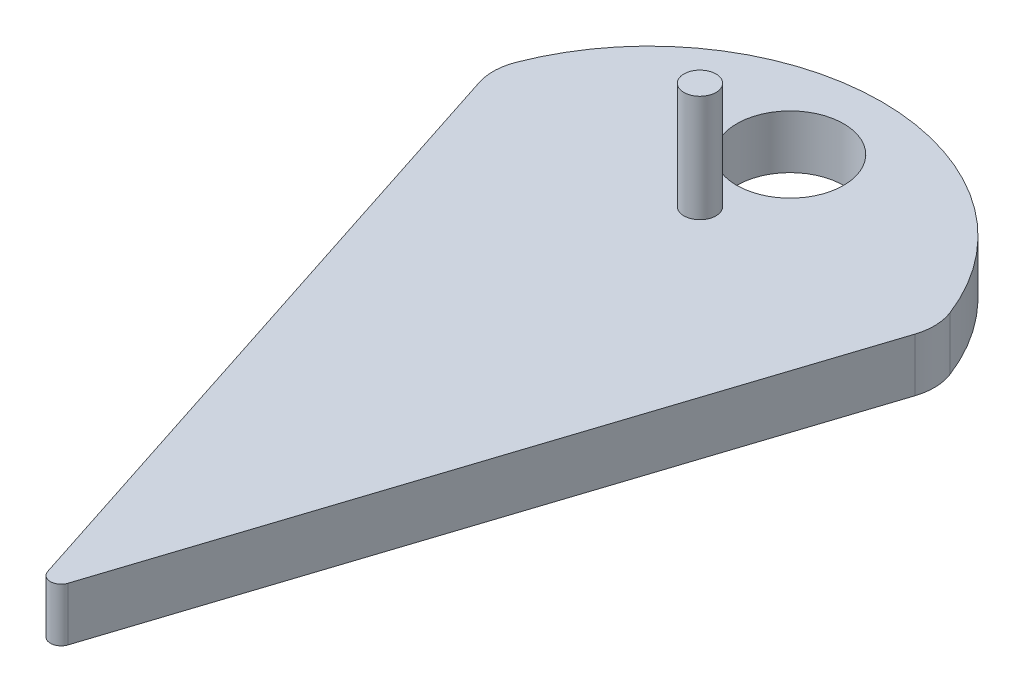
from build123d import *

# Parameters (mm, degrees)
SKETCH4_R           = 5
BOSS_EXTRUDE1_DEPTH = 5
SKETCH7_R           = 1.5
BOSS_EXTRUDE2_DEPTH = 10


with BuildPart() as part:
    # Sketch4 → Boss-Extrude1 (new body)
    with BuildSketch(Plane(origin=(0, 0, 0), x_dir=(1, 0, 0), z_dir=(0, 1, 0))):
        with BuildLine():
            Line((0.951056516, 2.927050983), (20.386221797, 62.74233921))
            ThreePointArc((20.386221797, 62.74233921), (20.629049199, 64.42488908), (20.294107239, 66.091548341))
            ThreePointArc((20.294107239, 66.091548341), (0, 80), (-20.294107239, 66.091548341))
            ThreePointArc((-20.294107239, 66.091548341), (-20.629049199, 64.42488908), (-20.386221797, 62.74233921))
            Line((-20.386221797, 62.74233921), (-0.951056516, 2.927050983))
            ThreePointArc((-0.951056516, 2.927050983), (0, 2.236067977), (0.951056516, 2.927050983))
        make_face()
        with Locations((0, 71.439)):
            Circle(SKETCH4_R, mode=Mode.SUBTRACT)
    extrude(amount=BOSS_EXTRUDE1_DEPTH)

    # Sketch7 → Boss-Extrude2 (add)
    with BuildSketch(Plane(origin=(0, 5, 0), x_dir=(1, 0, 0), z_dir=(0, 1, 0))):
        with Locations((0, 62.999)):
            Circle(SKETCH7_R)
    extrude(amount=BOSS_EXTRUDE2_DEPTH)


solid = part.part
